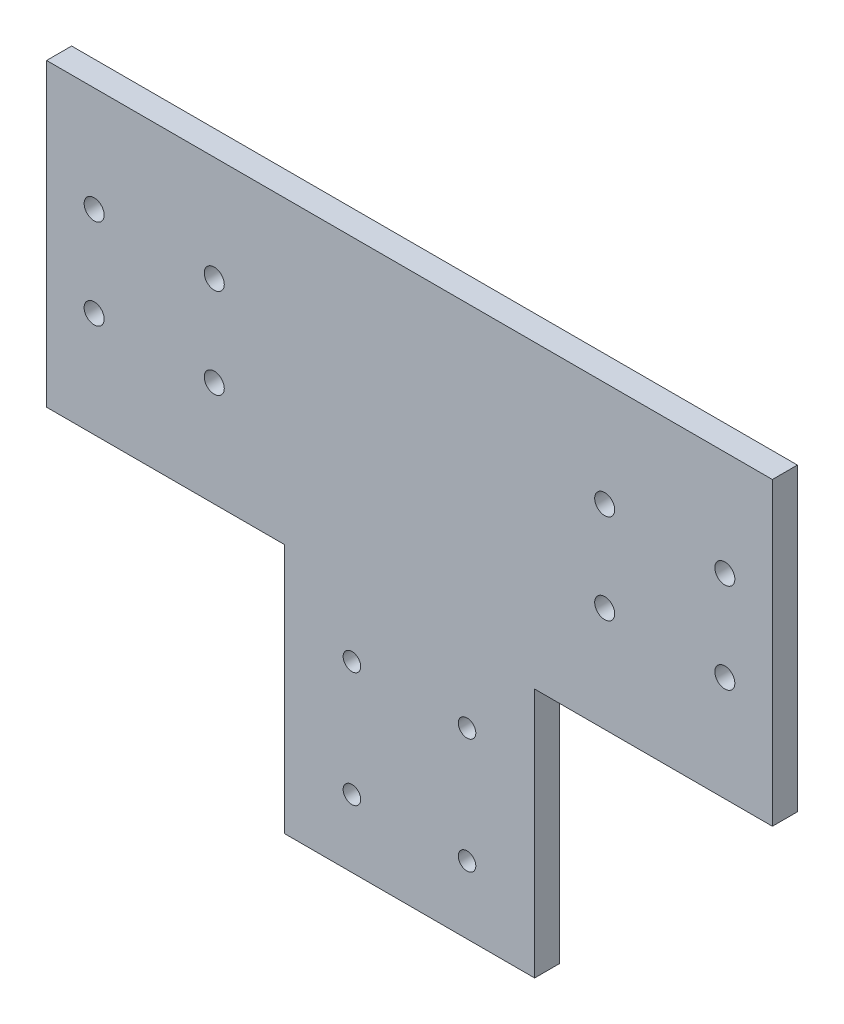
from build123d import *

# Parameters (mm, degrees)
SKETCH1_R           = 1.75
SKETCH1_R_2         = 2
BOSS_EXTRUDE1_DEPTH = 5


with BuildPart() as part:
    # Sketch1 → Boss-Extrude1 (new body)
    with BuildSketch(Plane.XY):
        Polygon((-72.5, 30), (72.5, 30), (72.5, -30), (25, -30), (25, -80), (-25, -80), (-25, -30), (-72.5, -30), align=None)
        with Locations((-11.5, -66.5)):
            Circle(SKETCH1_R, mode=Mode.SUBTRACT)
        with Locations((11.5, -66.5)):
            Circle(SKETCH1_R, mode=Mode.SUBTRACT)
        with Locations((11.5, -43.5)):
            Circle(SKETCH1_R, mode=Mode.SUBTRACT)
        with Locations((-11.5, -43.5)):
            Circle(SKETCH1_R, mode=Mode.SUBTRACT)
        with Locations((-63, 9)):
            Circle(SKETCH1_R_2, mode=Mode.SUBTRACT)
        with Locations((-39, 9)):
            Circle(SKETCH1_R_2, mode=Mode.SUBTRACT)
        with Locations((-39, -9)):
            Circle(SKETCH1_R_2, mode=Mode.SUBTRACT)
        with Locations((-63, -9)):
            Circle(SKETCH1_R_2, mode=Mode.SUBTRACT)
        with Locations((63, -9)):
            Circle(SKETCH1_R_2, mode=Mode.SUBTRACT)
        with Locations((39, -9)):
            Circle(SKETCH1_R_2, mode=Mode.SUBTRACT)
        with Locations((39, 9)):
            Circle(SKETCH1_R_2, mode=Mode.SUBTRACT)
        with Locations((63, 9)):
            Circle(SKETCH1_R_2, mode=Mode.SUBTRACT)
    extrude(amount=BOSS_EXTRUDE1_DEPTH)


solid = part.part
